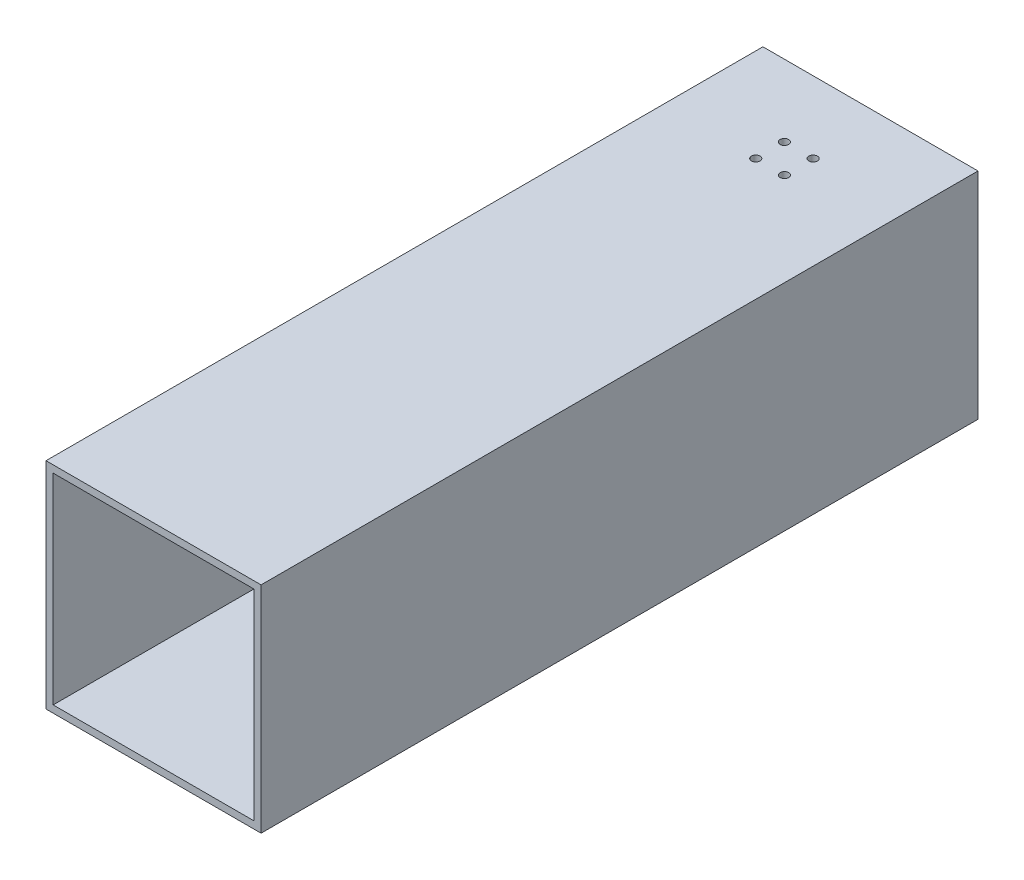
from build123d import *

# Parameters (mm, degrees)
SKETCH_1_W          = 150
SKETCH_1_H          = 150
EXTRUDE_1_DEPTH     = 500
SKETCH_2_W          = 140
SKETCH_2_H          = 140
CUT_EXTRUDE_1_DEPTH = 501
MM_1_D              = 6


with BuildPart() as part:
    # 草图1 → 凸台-拉伸1 (new body)
    with BuildSketch(Plane.XY):
        Rectangle(SKETCH_1_W, SKETCH_1_H)
    extrude(amount=EXTRUDE_1_DEPTH)

    # 草图2 → 切除-拉伸1 (cut, through all)
    with BuildSketch(Plane.XY.offset(500)):
        Rectangle(SKETCH_2_W, SKETCH_2_H)
    extrude(amount=-CUT_EXTRUDE_1_DEPTH, mode=Mode.SUBTRACT)

    # 大小mm 暗销孔1 (through all)
    with Locations(Plane(origin=(0, 75, 0), x_dir=(1, 0, 0), z_dir=(0, 1, 0))):
        with Locations((-10, -50), (10, -50), (10, -70), (-10, -70)):
            Hole(MM_1_D / 2)


solid = part.part
